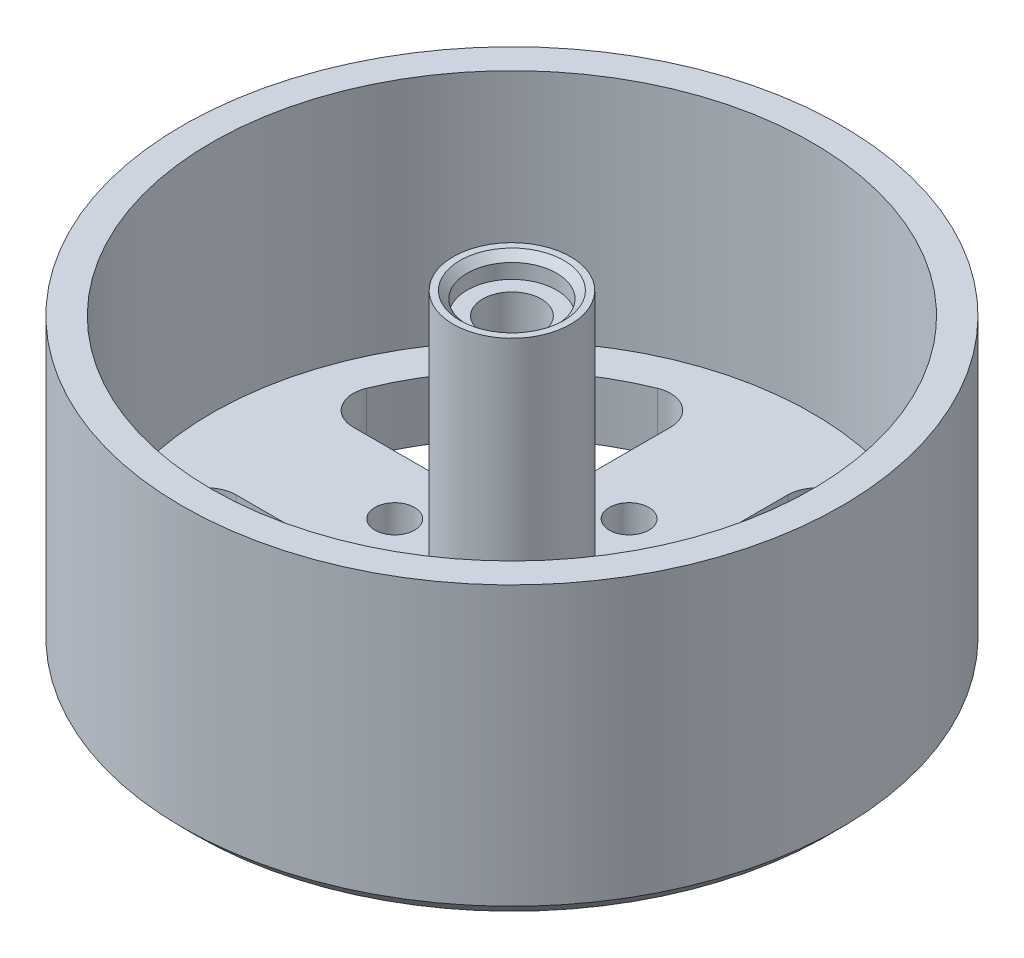
from build123d import *

# Parameters (mm, degrees)
SKETCH_1_R      = 20.5
SKETCH_1_R_2    = 1.35
SKETCH_1_R_3    = 4
EXTRUDE_1_DEPTH = 4
SKETCH_1_3_R    = 4
SKETCH_1_3_R_2  = 2
EXTRUDE_2_DEPTH = 20
SKETCH_1_4_R    = 22.5
SKETCH_1_4_R_2  = 20.5
EXTRUDE_3_DEPTH = 20
FILLET_1_R      = 5
FILLET_2_R      = 2
CHAMFER_1_SIZE  = 1
SKETCH_2_R      = 4
SKETCH_2_R_2    = 3.05
EXTRUDE_4_DEPTH = 1.5
CHAMFER_2_SIZE  = 0.5


with BuildPart() as part:
    # 草图1 → 凸台-拉伸1 (new body)
    with BuildSketch(Plane(origin=(0, 0, 0), x_dir=(1, 0, 0), z_dir=(0, 1, 0))):
        Circle(SKETCH_1_R)
        with BuildLine():
            Line((-4, -4), (-4, -17.549928775))
            ThreePointArc((-4, -17.549928775), (-12.727922061, -12.727922061), (-17.549928775, -4))
            Line((-17.549928775, -4), (-4, -4))
        make_face(mode=Mode.SUBTRACT)
        with Locations((0, -8)):
            Circle(SKETCH_1_R_2, mode=Mode.SUBTRACT)
        with BuildLine():
            Line((4, -4), (17.549928775, -4))
            ThreePointArc((17.549928775, -4), (12.727922061, -12.727922061), (4, -17.549928775))
            Line((4, -17.549928775), (4, -4))
        make_face(mode=Mode.SUBTRACT)
        with Locations((8, 0)):
            Circle(SKETCH_1_R_2, mode=Mode.SUBTRACT)
        with Locations((-8, 0)):
            Circle(SKETCH_1_R_2, mode=Mode.SUBTRACT)
        with BuildLine():
            Line((-4, 4), (-17.549928775, 4))
            ThreePointArc((-17.549928775, 4), (-12.727922061, 12.727922061), (-4, 17.549928775))
            Line((-4, 17.549928775), (-4, 4))
        make_face(mode=Mode.SUBTRACT)
        Circle(SKETCH_1_R_3, mode=Mode.SUBTRACT)
        with Locations((0, 8)):
            Circle(SKETCH_1_R_2, mode=Mode.SUBTRACT)
        with BuildLine():
            Line((4, 4), (4, 17.549928775))
            ThreePointArc((4, 17.549928775), (12.727922061, 12.727922061), (17.549928775, 4))
            Line((17.549928775, 4), (4, 4))
        make_face(mode=Mode.SUBTRACT)
    extrude(amount=EXTRUDE_1_DEPTH)

    # 草图1<3> → 凸台-拉伸2 (add)
    with BuildSketch(Plane(origin=(0, 0, 0), x_dir=(1, 0, 0), z_dir=(0, 1, 0))):
        Circle(SKETCH_1_3_R)
        Circle(SKETCH_1_3_R_2, mode=Mode.SUBTRACT)
    extrude(amount=EXTRUDE_2_DEPTH)

    # 草图1<4> → 凸台-拉伸3 (add)
    with BuildSketch(Plane(origin=(0, 0, 0), x_dir=(1, 0, 0), z_dir=(0, 1, 0))):
        Circle(SKETCH_1_4_R)
        Circle(SKETCH_1_4_R_2, mode=Mode.SUBTRACT)
    extrude(amount=EXTRUDE_3_DEPTH)

    # 圆角1
    fillet_1_edges = [part.edges().sort_by_distance(p)[0] for p in [
        (-4, 2, 4),
        (4, 2, 4),
        (4, 2, -4),
        (-4, 2, -4),
    ]]
    fillet(fillet_1_edges, radius=FILLET_1_R)

    # 圆角2
    fillet_2_edges = [part.edges().sort_by_distance(p)[0] for p in [
        (4, 2, 17.549928775),
        (17.549928775, 2, 4),
        (17.549928775, 2, -4),
        (4, 2, -17.549928775),
        (-4, 2, 17.549928775),
        (-17.549928775, 2, 4),
        (-4, 2, -17.549928775),
        (-17.549928775, 2, -4),
    ]]
    fillet(fillet_2_edges, radius=FILLET_2_R)

    # 倒角1
    chamfer_1_edges = [part.edges().sort_by_distance(p)[0] for p in [
        (-22.5, 0, 0),
    ]]
    chamfer(chamfer_1_edges, length=CHAMFER_1_SIZE)

    # 草图2 → 凸台-拉伸4 (add)
    with BuildSketch(Plane(origin=(0, 20, 0), x_dir=(1, 0, 0), z_dir=(0, 1, 0))):
        Circle(SKETCH_2_R)
        Circle(SKETCH_2_R_2, mode=Mode.SUBTRACT)
    extrude(amount=EXTRUDE_4_DEPTH)

    # 倒角2
    chamfer_2_edges = [part.edges().sort_by_distance(p)[0] for p in [
        (-3.05, 21.5, 0),
    ]]
    chamfer(chamfer_2_edges, length=CHAMFER_2_SIZE)


solid = part.part
